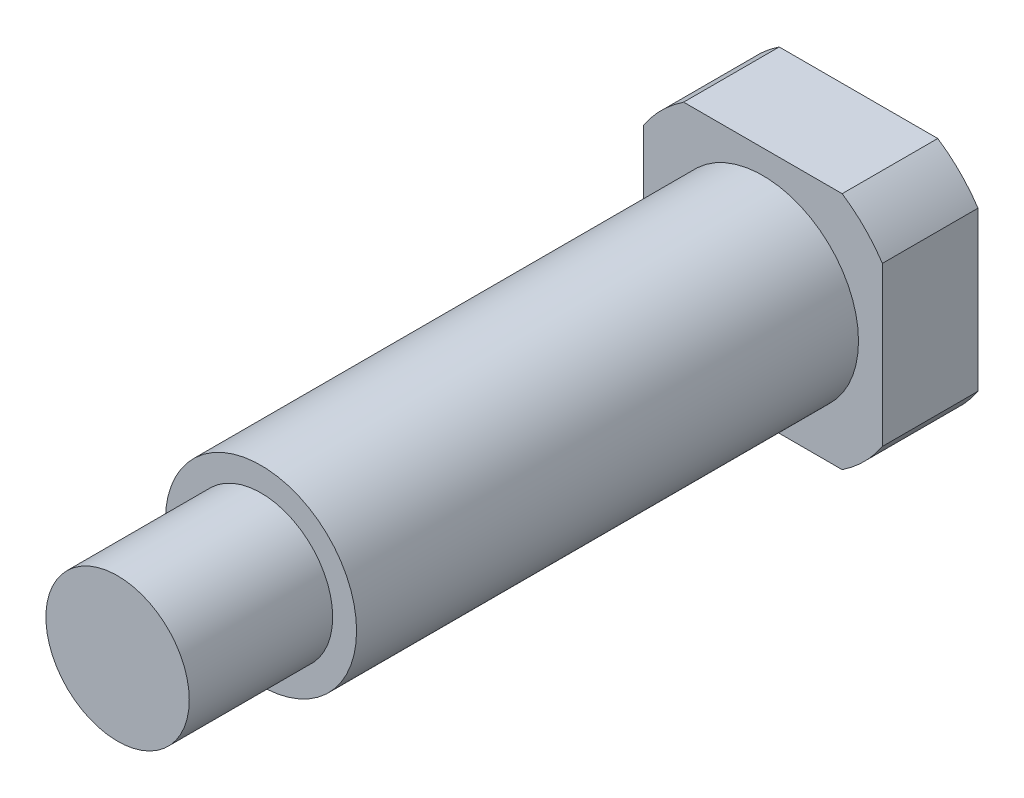
from build123d import *

# Parameters (mm, degrees)
SKETCH_1_R          = 6
EXTRUDE_1_DEPTH     = 4
SKETCH_2_R          = 4
EXTRUDE_2_DEPTH     = 21
SKETCH_3_R          = 3
EXTRUDE_3_DEPTH     = 6
SKETCH_4_R          = 7.5
SKETCH_4_W          = 10
SKETCH_4_H          = 10
CUT_EXTRUDE_1_DEPTH = 6


with BuildPart() as part:
    # 草图1 → 凸台-拉伸1 (new body)
    with BuildSketch(Plane.XY):
        Circle(SKETCH_1_R)
    extrude(amount=EXTRUDE_1_DEPTH)

    # 草图2 → 凸台-拉伸2 (add)
    with BuildSketch(Plane.XY.offset(4)):
        Circle(SKETCH_2_R)
    extrude(amount=EXTRUDE_2_DEPTH)

    # 草图3 → 凸台-拉伸3 (add)
    with BuildSketch(Plane.XY.offset(25)):
        Circle(SKETCH_3_R)
    extrude(amount=EXTRUDE_3_DEPTH)

    # 草图4 → 切除-拉伸1 (cut)
    with BuildSketch(Plane(origin=(0, 0, 0), x_dir=(-1, 0, 0), z_dir=(0, 0, -1))):
        Circle(SKETCH_4_R)
        Rectangle(SKETCH_4_W, SKETCH_4_H, mode=Mode.SUBTRACT)
    extrude(amount=-CUT_EXTRUDE_1_DEPTH, mode=Mode.SUBTRACT)


solid = part.part
